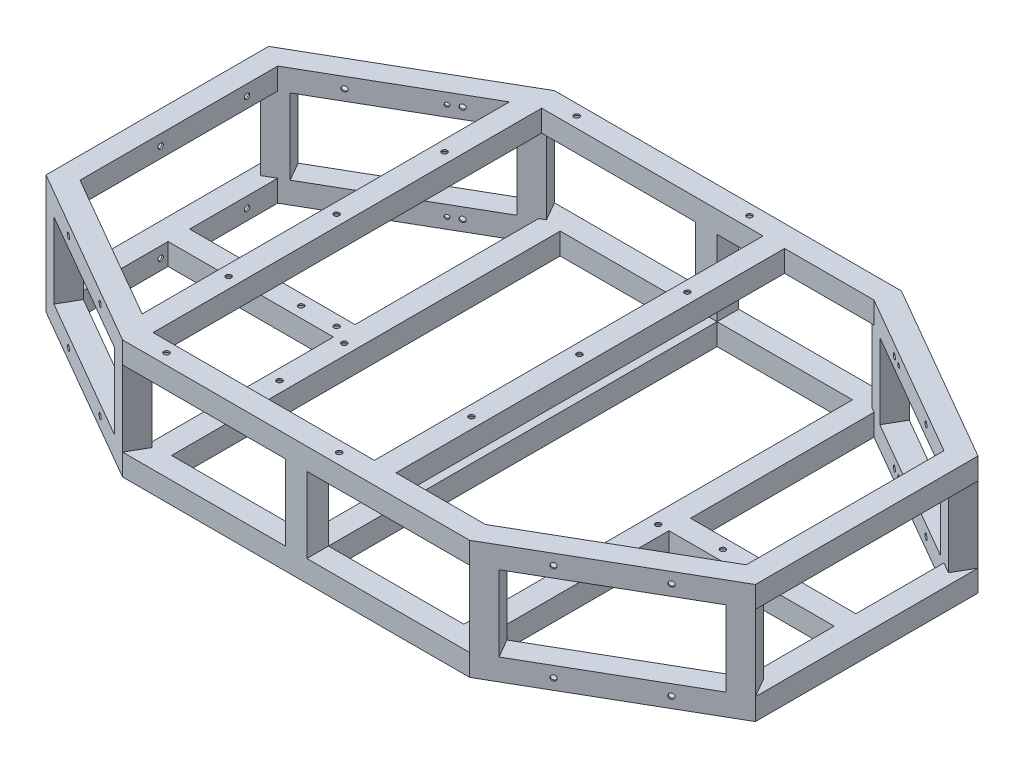
from build123d import *

# Parameters (mm, degrees)
SKETCH2_W                             = 25.4
SKETCH2_H                             = 25.4
SKETCH2_W_2                           = 22.098
SKETCH2_H_2                           = 22.098
VERTICAL_MEMBER_1_DEPTH               = 88.9
VERTICAL_MEMBER_2_DEPTH               = 88.9
VERTICAL_MEMBERS_5_6_7_8_COPY_1_DEPTH = 88.9
VERTICAL_MEMBERS_5_6_7_8_COPY_2_DEPTH = 88.9
SKETCH6_W                             = 25.4
SKETCH6_H                             = 25.4
SKETCH6_W_2                           = 22.098
SKETCH6_H_2                           = 22.098
MIDDLE_VERTICAL_MEMBER_1_DEPTH        = 88.9
SKETCH7_W                             = 25.4
SKETCH7_H                             = 25.4
SKETCH7_W_2                           = 22.098
SKETCH7_H_2                           = 22.098
MIDDLE_SUPPORT_DEPTH                  = 457.2
SKETCH8_W                             = 25.4
SKETCH8_H                             = 25.4
SKETCH8_W_2                           = 22.098
SKETCH8_H_2                           = 22.098
BOTTOM_SUPPORT_REAR_DEPTH             = 457.2
SKETCH9_W                             = 25.4
SKETCH9_H                             = 25.4
SKETCH9_W_2                           = 22.098
SKETCH9_H_2                           = 22.098
I_BEAM_DEPTH                          = 194.570453
SKETCH10_W                            = 25.4
SKETCH10_H                            = 25.4
SKETCH10_W_2                          = 22.098
SKETCH10_H_2                          = 22.098
TOP_REAR_SUPPORT_DEPTH                = 457.2
F_1_4_0_25_DIAMETER_HOLE_1_D          = 6.35
F_1_4_0_25_DIAMETER_HOLE_3_AT_2_COUNT = 2
F_1_4_0_25_DIAMETER_HOLE_3_AT_2_PITCH = 203.2
F_1_4_0_25_DIAMETER_HOLE3_AT_2_COUNT  = 2
F_1_4_0_25_DIAMETER_HOLE3_AT_2_PITCH  = 101.6
SKETCH22_R                            = 2.54
INNER_HOLE_LOCATION_1_DEPTH           = 6.35
INNER_HOLE_LOCATION_3_COPY_1_SKETCH_R = 2.54
INNER_HOLE_LOCATION_3_COPY_1_DEPTH    = 6.35
INNER_HOLE_LOCATION_4_COPY_1_SKETCH_R = 2.54
INNER_HOLE_LOCATION_4_COPY_1_DEPTH    = 6.35
INNER_HOLE_LOCATION_4_COPY_2_SKETCH_R = 2.54
INNER_HOLE_LOCATION_4_COPY_2_DEPTH    = 6.35
INNER_HOLE_LOCATION_4_COPY_3_SKETCH_R = 2.54
INNER_HOLE_LOCATION_4_COPY_3_DEPTH    = 6.35
SKETCH23_R                            = 3.175
REAR_SHOCK_MOUNT_HOLES_DEPTH          = 26.4
SKETCH24_R                            = 1.2446
Z_DIRECTION_HOLES_DEPTH               = 1.651
SKETCH25_R                            = 1.2446
X_DIRECTION_HOLES_DEPTH               = 1.651
SKETCH26_R                            = 3.175
REAR_HOLES_DEPTH                      = 25.4
SKETCH27_R                            = 1.2446
CUT_EXTRUDE5_DEPTH                    = 1.651


with BuildPart() as part:
    # Bottom Frame: sweep along a path in Sketch3
    with BuildLine(Plane(origin=(0, 0, 0), x_dir=(1, 0, 0), z_dir=(0, 1, 0))) as bottom_frame_path:
        Line((-190.5, 203.2), (190.5, 203.2))
        Line((190.5, 203.2), (366.476362049, 101.6))
        Line((366.476362049, 101.6), (366.476362049, -101.6))
        Line((366.476362049, -101.6), (190.5, -203.2))
        Line((190.5, -203.2), (-190.5, -203.2))
        Line((-190.5, -203.2), (-366.476362049, -101.6))
        Line((-366.476362049, -101.6), (-366.476362049, 101.6))
        Line((-366.476362049, 101.6), (-190.5, 203.2))
    # Sketch2 → Bottom Frame (sweep)
    with BuildSketch(Plane(origin=(0, 0, 0), x_dir=(0, 0, -1), z_dir=(1, 0, 0))):
        with Locations((241.3, 0)):
            Rectangle(SKETCH2_W, SKETCH2_H)
        with Locations((241.3, 0)):
            Rectangle(SKETCH2_W_2, SKETCH2_H_2, mode=Mode.SUBTRACT)
    bottom_frame = sweep(path=bottom_frame_path.line, transition=Transition.RIGHT)

    # Sketch4 → Vertical Member 1 (add)
    with BuildSketch(Plane(origin=(0, 12.7, 0), x_dir=(1, 0, 0), z_dir=(0, 1, 0))):
        Polygon((-204.111818976, -254), (-226.108864232, -241.3), (-213.408864232, -219.302954744), (-191.411818976, -232.002954744), align=None)
        Polygon((-204.716126917, -251.744692058), (-223.85355629, -240.695692058), (-212.80455629, -221.558262686), (-193.667126917, -232.607262686), align=None, mode=Mode.SUBTRACT)
    vertical_member_1 = extrude(amount=VERTICAL_MEMBER_1_DEPTH)

    # Sketch5 → Vertical Member 2 (add)
    with BuildSketch(Plane(origin=(0, 12.7, 0), x_dir=(1, 0, 0), z_dir=(0, 1, 0))):
        Polygon((-417.276362049, -130.929393675), (-395.279316793, -143.629393675), (-382.579316793, -121.632348419), (-404.576362049, -108.932348419), align=None)
        Polygon((-415.021054107, -130.325085733), (-395.883624735, -141.374085733), (-384.834624735, -122.23665636), (-403.972054107, -111.18765636), align=None, mode=Mode.SUBTRACT)
    vertical_member_2 = extrude(amount=VERTICAL_MEMBER_2_DEPTH)

    # Vertical Member 3 & 4: Vertical Member 1, Vertical Member 2 across plane
    add(vertical_member_1.mirror(Plane.XY))
    add(vertical_member_2.mirror(Plane.XY))

    # Vertical Members 5, 6, 7, 8: Vertical Member 1, Vertical Member 2 across plane
    add(vertical_member_1.mirror(Plane(origin=(0, 0, 0), x_dir=(0, 0, 1), z_dir=(1, 0, 0))))
    add(vertical_member_2.mirror(Plane(origin=(0, 0, 0), x_dir=(0, 0, 1), z_dir=(1, 0, 0))))

    # Vertical Members 5, 6, 7, 8 copy 1 sketc → Vertical Members 5, 6, 7, 8 copy 1 (add)
    with BuildSketch(Plane(origin=(0, 12.7, 0), x_dir=(-1, 0, 0), z_dir=(0, 1, 0))):
        Polygon((-204.111818976, -254), (-226.108864232, -241.3), (-213.408864232, -219.302954744), (-191.411818976, -232.002954744), align=None)
        Polygon((-204.716126917, -251.744692058), (-223.85355629, -240.695692058), (-212.80455629, -221.558262686), (-193.667126917, -232.607262686), align=None, mode=Mode.SUBTRACT)
    extrude(amount=VERTICAL_MEMBERS_5_6_7_8_COPY_1_DEPTH)

    # Vertical Members 5, 6, 7, 8 copy 2 sketc → Vertical Members 5, 6, 7, 8 copy 2 (add)
    with BuildSketch(Plane(origin=(0, 12.7, 0), x_dir=(-1, 0, 0), z_dir=(0, 1, 0))):
        Polygon((-417.276362049, -130.929393675), (-395.279316793, -143.629393675), (-382.579316793, -121.632348419), (-404.576362049, -108.932348419), align=None)
        Polygon((-415.021054107, -130.325085733), (-395.883624735, -141.374085733), (-384.834624735, -122.23665636), (-403.972054107, -111.18765636), align=None, mode=Mode.SUBTRACT)
    extrude(amount=VERTICAL_MEMBERS_5_6_7_8_COPY_2_DEPTH)

    # Sketch6 → Middle Vertical Member 1 (add)
    with BuildSketch(Plane(origin=(0, 12.7, 0), x_dir=(1, 0, 0), z_dir=(0, 1, 0))):
        with Locations((0, -241.3)):
            Rectangle(SKETCH6_W, SKETCH6_H)
        with Locations((0, -241.3)):
            Rectangle(SKETCH6_W_2, SKETCH6_H_2, mode=Mode.SUBTRACT)
    middle_vertical_member_1 = extrude(amount=MIDDLE_VERTICAL_MEMBER_1_DEPTH)

    # Middle Vertical Member 2: Middle Vertical Member 1 across plane
    add(middle_vertical_member_1.mirror(Plane.XY))

    # Top Frame: Bottom Frame across plane
    add(bottom_frame.mirror(Plane.ZX.offset(57.15)))

    # Sketch7 → Middle Support (add)
    with BuildSketch(Plane(origin=(0, 0, 228.6), x_dir=(-1, 0, 0), z_dir=(0, 0, -1))):
        Rectangle(SKETCH7_W, SKETCH7_H)
        Rectangle(SKETCH7_W_2, SKETCH7_H_2, mode=Mode.SUBTRACT)
    extrude(amount=MIDDLE_SUPPORT_DEPTH)

    # Sketch8 → Bottom Support Rear (add)
    with BuildSketch(Plane(origin=(0, 0, 228.6), x_dir=(-1, 0, 0), z_dir=(0, 0, -1))):
        with Locations((184.605909488, 0)):
            Rectangle(SKETCH8_W, SKETCH8_H)
        with Locations((184.605909488, 0)):
            Rectangle(SKETCH8_W_2, SKETCH8_H_2, mode=Mode.SUBTRACT)
    bottom_support_rear = extrude(amount=BOTTOM_SUPPORT_REAR_DEPTH)

    # Sketch9 → I Beam (add)
    with BuildSketch(Plane(origin=(-391.876362049, 0, 0), x_dir=(0, 0, -1), z_dir=(1, 0, 0))):
        Rectangle(SKETCH9_W, SKETCH9_H)
        Rectangle(SKETCH9_W_2, SKETCH9_H_2, mode=Mode.SUBTRACT)
    i_beam = extrude(amount=I_BEAM_DEPTH)

    # Bottom Support Front w/ I Beam: Bottom Support Rear, I Beam across plane
    add(bottom_support_rear.mirror(Plane(origin=(0, 0, 0), x_dir=(0, 0, 1), z_dir=(1, 0, 0))))
    add(i_beam.mirror(Plane(origin=(0, 0, 0), x_dir=(0, 0, 1), z_dir=(1, 0, 0))))

    # Sketch10 → Top Rear Support (add)
    with BuildSketch(Plane(origin=(0, 0, 228.6), x_dir=(-1, 0, 0), z_dir=(0, 0, -1))):
        with Locations((206.375, 114.3)):
            Rectangle(SKETCH10_W, SKETCH10_H)
        with Locations((206.375, 114.3)):
            Rectangle(SKETCH10_W_2, SKETCH10_H_2, mode=Mode.SUBTRACT)
    top_rear_support = extrude(amount=TOP_REAR_SUPPORT_DEPTH)

    # Top Front Support: Top Rear Support across plane
    add(top_rear_support.mirror(Plane(origin=(-63.5, 0, 0), x_dir=(0, 0, 1), z_dir=(1, 0, 0))))

    # 1/4 (0.25) Diameter Hole 1 (through all)
    with Locations(Plane(origin=(0, 127, 0), x_dir=(1, 0, 0), z_dir=(0, 1, 0))):
        with Locations((-206.375, 127), (-206.375, -127), (-206.375, 0)):
            f_1_4_0_25_diameter_hole_1 = Hole(F_1_4_0_25_DIAMETER_HOLE_1_D / 2)

    # 1/4 (0.25) Diameter Hole 2: 1/4 (0.25) Diameter Hole 1 across plane
    add(f_1_4_0_25_diameter_hole_1.mirror(Plane(origin=(-63.5, 0, 0), x_dir=(0, 0, 1), z_dir=(1, 0, 0))), mode=Mode.SUBTRACT)

    # Sketch17 → 1/4 (0.25) Diameter Hole 3 (revolve, cut)
    with BuildSketch(Plane(origin=(-165.1, 127, 241.3), x_dir=(0, 0, 1), z_dir=(1, 0, 0))):
        Polygon((0, 0), (0, 52.707732465), (3.175, 50.8), (3.175, 0), align=None)
    f_1_4_0_25_diameter_hole_3 = revolve(axis=Axis((-165.1, 133.35, 241.3), (0, -1, 0)), mode=Mode.SUBTRACT)

    # 1/4 (0.25) Diameter Hole 3 at 2: 1/4 (0.25) Diameter Hole 3 ×2
    with Locations(*[(i * F_1_4_0_25_DIAMETER_HOLE_3_AT_2_PITCH, 0, 0) for i in range(1, F_1_4_0_25_DIAMETER_HOLE_3_AT_2_COUNT)]):
        add(f_1_4_0_25_diameter_hole_3, mode=Mode.SUBTRACT)

    # 1/4 (0.25) Diameter Hole 4: 1/4 (0.25) Diameter Hole 3 across plane
    add(f_1_4_0_25_diameter_hole_3.mirror(Plane.XY), mode=Mode.SUBTRACT)

    # 1/4 (0.25) Diameter Hole 4 copy 1 sketch → 1/4 (0.25) Diameter Hole 4 copy 1 (revolve, cut)
    with BuildSketch(Plane(origin=(38.1, 127, -241.3), x_dir=(0, 0, -1), z_dir=(1, 0, 0))):
        Polygon((0, 0), (0, -52.707732465), (3.175, -50.8), (3.175, 0), align=None)
    revolve(axis=Axis((38.1, 133.35, -241.3), (0, 1, 0)), mode=Mode.SUBTRACT)

    # Sketch20 → 1/4 (0.25) Diameter Hole3 (revolve, cut)
    with BuildSketch(Plane(origin=(-354.688181024, 114.3, 167.064696837), x_dir=(0.866025404, 0, 0.5), z_dir=(0, 1, 0))):
        Polygon((0, 0), (0, 52.707732465), (3.175, 50.8), (3.175, 0), align=None)
    f_1_4_0_25_diameter_hole3 = revolve(axis=Axis((-357.863181024, 114.3, 172.563958151), (0.5, 0, -0.866025404)), mode=Mode.SUBTRACT)

    # 1/4 (0.25) Diameter Hole3 at 2: 1/4 (0.25) Diameter Hole3 ×2
    with Locations(*[Vector(0.866025404, 0, 0.5) * (i * F_1_4_0_25_DIAMETER_HOLE3_AT_2_PITCH) for i in range(1, F_1_4_0_25_DIAMETER_HOLE3_AT_2_COUNT)]):
        add(f_1_4_0_25_diameter_hole3, mode=Mode.SUBTRACT)

    # Hole Location 1: 1/4 (0.25) Diameter Hole3 across plane
    add(f_1_4_0_25_diameter_hole3.mirror(Plane.ZX.offset(57.15)), mode=Mode.SUBTRACT)

    # Hole Location 1 copy 1 sketch → Hole Location 1 copy 1 (revolve, cut)
    with BuildSketch(Plane(origin=(-266.7, 0, 217.864696837), x_dir=(0.866025404, 0, 0.5), z_dir=(0, -1, 0))):
        Polygon((0, 0), (0, -52.707732465), (3.175, -50.8), (3.175, 0), align=None)
    revolve(axis=Axis((-269.875, 0, 223.363958151), (-0.5, 0, 0.866025404)), mode=Mode.SUBTRACT)

    # Hole Location 2: 1/4 (0.25) Diameter Hole3 across plane
    add(f_1_4_0_25_diameter_hole3.mirror(Plane.XY), mode=Mode.SUBTRACT)

    # Hole Location 2 copy 1 sketch → Hole Location 2 copy 1 (revolve, cut)
    with BuildSketch(Plane(origin=(-354.688181024, 0, -167.064696837), x_dir=(0.866025404, 0, -0.5), z_dir=(0, -1, 0))):
        Polygon((0, 0), (0, 52.707732465), (3.175, 50.8), (3.175, 0), align=None)
    revolve(axis=Axis((-357.863181024, 0, -172.563958151), (0.5, 0, 0.866025404)), mode=Mode.SUBTRACT)

    # Hole Location 2 copy 2 sketch → Hole Location 2 copy 2 (revolve, cut)
    with BuildSketch(Plane(origin=(-266.7, 0, -217.864696837), x_dir=(0.866025404, 0, -0.5), z_dir=(0, -1, 0))):
        Polygon((0, 0), (0, 52.707732465), (3.175, 50.8), (3.175, 0), align=None)
    revolve(axis=Axis((-269.875, 0, -223.363958151), (0.5, 0, 0.866025404)), mode=Mode.SUBTRACT)

    # Hole Location 2 copy 3 sketch → Hole Location 2 copy 3 (revolve, cut)
    with BuildSketch(Plane(origin=(-266.7, 114.3, -217.864696837), x_dir=(0.866025404, 0, -0.5), z_dir=(0, 1, 0))):
        Polygon((0, 0), (0, -52.707732465), (3.175, -50.8), (3.175, 0), align=None)
    revolve(axis=Axis((-269.875, 114.3, -223.363958151), (-0.5, 0, -0.866025404)), mode=Mode.SUBTRACT)

    # Hole Location 3: 1/4 (0.25) Diameter Hole3 across plane
    add(f_1_4_0_25_diameter_hole3.mirror(Plane(origin=(0, 0, 0), x_dir=(0, 0, 1), z_dir=(1, 0, 0))), mode=Mode.SUBTRACT)

    # Hole Location 3 copy 1 sketch → Hole Location 3 copy 1 (revolve, cut)
    with BuildSketch(Plane(origin=(354.688181024, 114.3, -167.064696837), x_dir=(-0.866025404, 0, -0.5), z_dir=(0, 1, 0))):
        Polygon((0, 0), (0, 52.707732465), (3.175, 50.8), (3.175, 0), align=None)
    revolve(axis=Axis((357.863181024, 114.3, -172.563958151), (-0.5, 0, 0.866025404)), mode=Mode.SUBTRACT)

    # Hole Location 3 copy 2 sketch → Hole Location 3 copy 2 (revolve, cut)
    with BuildSketch(Plane(origin=(354.688181024, 0, -167.064696837), x_dir=(-0.866025404, 0, -0.5), z_dir=(0, -1, 0))):
        Polygon((0, 0), (0, -52.707732465), (3.175, -50.8), (3.175, 0), align=None)
    revolve(axis=Axis((357.863181024, 0, -172.563958151), (0.5, 0, -0.866025404)), mode=Mode.SUBTRACT)

    # Hole Location 3 copy 3 sketch → Hole Location 3 copy 3 (revolve, cut)
    with BuildSketch(Plane(origin=(266.7, 0, -217.864696837), x_dir=(-0.866025404, 0, -0.5), z_dir=(0, -1, 0))):
        Polygon((0, 0), (0, -52.707732465), (3.175, -50.8), (3.175, 0), align=None)
    revolve(axis=Axis((269.875, 0, -223.363958151), (0.5, 0, -0.866025404)), mode=Mode.SUBTRACT)

    # Hole Location 3 copy 4 sketch → Hole Location 3 copy 4 (revolve, cut)
    with BuildSketch(Plane(origin=(266.7, 114.3, -217.864696837), x_dir=(-0.866025404, 0, -0.5), z_dir=(0, 1, 0))):
        Polygon((0, 0), (0, 52.707732465), (3.175, 50.8), (3.175, 0), align=None)
    revolve(axis=Axis((269.875, 114.3, -223.363958151), (-0.5, 0, 0.866025404)), mode=Mode.SUBTRACT)

    # Hole Location 3 copy 5 sketch → Hole Location 3 copy 5 (revolve, cut)
    with BuildSketch(Plane(origin=(266.7, 114.3, 217.864696837), x_dir=(-0.866025404, 0, 0.5), z_dir=(0, 1, 0))):
        Polygon((0, 0), (0, -52.707732465), (3.175, -50.8), (3.175, 0), align=None)
    revolve(axis=Axis((269.875, 114.3, 223.363958151), (0.5, 0, 0.866025404)), mode=Mode.SUBTRACT)

    # Hole Location 3 copy 6 sketch → Hole Location 3 copy 6 (revolve, cut)
    with BuildSketch(Plane(origin=(354.688181024, 0, 167.064696837), x_dir=(-0.866025404, 0, 0.5), z_dir=(0, -1, 0))):
        Polygon((0, 0), (0, 52.707732465), (3.175, 50.8), (3.175, 0), align=None)
    revolve(axis=Axis((357.863181024, 0, 172.563958151), (-0.5, 0, -0.866025404)), mode=Mode.SUBTRACT)

    # Hole Location 3 copy 7 sketch → Hole Location 3 copy 7 (revolve, cut)
    with BuildSketch(Plane(origin=(266.7, 0, 217.864696837), x_dir=(-0.866025404, 0, 0.5), z_dir=(0, -1, 0))):
        Polygon((0, 0), (0, 52.707732465), (3.175, 50.8), (3.175, 0), align=None)
    revolve(axis=Axis((269.875, 0, 223.363958151), (-0.5, 0, -0.866025404)), mode=Mode.SUBTRACT)

    # Sketch22 → Inner Hole Location 1 (cut)
    with BuildSketch(Plane(origin=(-148.313181024, 0, -256.885964967), x_dir=(0.866025404, 0, -0.5), z_dir=(0.5, 0, 0.866025404))):
        with Locations((-135.491020445, 114.3)):
            Circle(SKETCH22_R)
        with Locations((10.558979555, 114.3)):
            Circle(SKETCH22_R)
    inner_hole_location_1 = extrude(amount=-INNER_HOLE_LOCATION_1_DEPTH, mode=Mode.SUBTRACT)

    # Inner Hole Location 2: Inner Hole Location 1 across plane
    add(inner_hole_location_1.mirror(Plane.ZX.offset(57.15)), mode=Mode.SUBTRACT)

    # Inner Hole Location 3: Inner Hole Location 1 across plane
    add(inner_hole_location_1.mirror(Plane.XY), mode=Mode.SUBTRACT)

    # Inner Hole Location 3 copy 1 sketch → Inner Hole Location 3 copy 1 (cut)
    with BuildSketch(Plane(origin=(-148.313181024, 114.3, 256.885964967), x_dir=(0.866025404, 0, 0.5), z_dir=(0.5, 0, -0.866025404))):
        with Locations((-135.491020445, 114.3)):
            Circle(INNER_HOLE_LOCATION_3_COPY_1_SKETCH_R)
        with Locations((10.558979555, 114.3)):
            Circle(INNER_HOLE_LOCATION_3_COPY_1_SKETCH_R)
    extrude(amount=-INNER_HOLE_LOCATION_3_COPY_1_DEPTH, mode=Mode.SUBTRACT)

    # Inner Hole Location 4: Inner Hole Location 1 across plane
    add(inner_hole_location_1.mirror(Plane(origin=(0, 0, 0), x_dir=(0, 0, 1), z_dir=(1, 0, 0))), mode=Mode.SUBTRACT)

    # Inner Hole Location 4 copy 1 sketch → Inner Hole Location 4 copy 1 (cut)
    with BuildSketch(Plane(origin=(148.313181024, 0, 256.885964967), x_dir=(-0.866025404, 0, 0.5), z_dir=(-0.5, 0, -0.866025404))):
        with Locations((-135.491020445, 114.3)):
            Circle(INNER_HOLE_LOCATION_4_COPY_1_SKETCH_R)
        with Locations((10.558979555, 114.3)):
            Circle(INNER_HOLE_LOCATION_4_COPY_1_SKETCH_R)
    extrude(amount=-INNER_HOLE_LOCATION_4_COPY_1_DEPTH, mode=Mode.SUBTRACT)

    # Inner Hole Location 4 copy 2 sketch → Inner Hole Location 4 copy 2 (cut)
    with BuildSketch(Plane(origin=(148.313181024, 114.3, 256.885964967), x_dir=(-0.866025404, 0, 0.5), z_dir=(-0.5, 0, -0.866025404))):
        with Locations((-135.491020445, -114.3)):
            Circle(INNER_HOLE_LOCATION_4_COPY_2_SKETCH_R)
        with Locations((10.558979555, -114.3)):
            Circle(INNER_HOLE_LOCATION_4_COPY_2_SKETCH_R)
    extrude(amount=-INNER_HOLE_LOCATION_4_COPY_2_DEPTH, mode=Mode.SUBTRACT)

    # Inner Hole Location 4 copy 3 sketch → Inner Hole Location 4 copy 3 (cut)
    with BuildSketch(Plane(origin=(148.313181024, 114.3, -256.885964967), x_dir=(-0.866025404, 0, -0.5), z_dir=(-0.5, 0, 0.866025404))):
        with Locations((-135.491020445, 114.3)):
            Circle(INNER_HOLE_LOCATION_4_COPY_3_SKETCH_R)
        with Locations((10.558979555, 114.3)):
            Circle(INNER_HOLE_LOCATION_4_COPY_3_SKETCH_R)
    extrude(amount=-INNER_HOLE_LOCATION_4_COPY_3_DEPTH, mode=Mode.SUBTRACT)

    # Sketch23 → Rear Shock Mount Holes (cut, through all)
    with BuildSketch(Plane(origin=(0, 12.7, 0), x_dir=(1, 0, 0), z_dir=(0, 1, 0))):
        with Locations((-248.105909488, 0)):
            Circle(SKETCH23_R)
        with Locations((-184.605909488, -88.9)):
            Circle(SKETCH23_R)
        with Locations((-184.605909488, -12.7)):
            Circle(SKETCH23_R)
    rear_shock_mount_holes = extrude(amount=-REAR_SHOCK_MOUNT_HOLES_DEPTH, mode=Mode.SUBTRACT)

    # Front Shock Mount Holes: Rear Shock Mount Holes across plane
    add(rear_shock_mount_holes.mirror(Plane(origin=(0, 0, 0), x_dir=(0, 0, 1), z_dir=(1, 0, 0))), mode=Mode.SUBTRACT)

    # Sketch24 → Z Direction Holes (cut)
    with BuildSketch(Plane.XZ.offset(-101.6)):
        with Locations((-206.375, 190.5)):
            Circle(SKETCH24_R)
        with Locations((-206.375, 165.1)):
            Circle(SKETCH24_R)
        with Locations((-206.375, 63.5)):
            Circle(SKETCH24_R)
        with Locations((-206.375, 38.1)):
            Circle(SKETCH24_R)
        with Locations((-206.375, -165.1)):
            Circle(SKETCH24_R)
        with Locations((-206.375, -190.5)):
            Circle(SKETCH24_R)
        with Locations((79.375, 190.5)):
            Circle(SKETCH24_R)
        with Locations((79.375, 165.1)):
            Circle(SKETCH24_R)
        with Locations((79.375, 63.5)):
            Circle(SKETCH24_R)
        with Locations((79.375, 38.1)):
            Circle(SKETCH24_R)
        with Locations((79.375, -165.1)):
            Circle(SKETCH24_R)
        with Locations((79.375, -190.5)):
            Circle(SKETCH24_R)
    extrude(amount=-Z_DIRECTION_HOLES_DEPTH, mode=Mode.SUBTRACT)

    # Sketch25 → X Direction Holes (cut)
    with BuildSketch(Plane.XZ.offset(-101.6)):
        with Locations((75.288181024, -241.3)):
            Circle(SKETCH25_R)
        with Locations((49.888181024, -241.3)):
            Circle(SKETCH25_R)
        with Locations((-176.888181024, -241.3)):
            Circle(SKETCH25_R)
        with Locations((-202.288181024, -241.3)):
            Circle(SKETCH25_R)
        with Locations((-176.888181024, 241.3)):
            Circle(SKETCH25_R)
        with Locations((-202.288181024, 241.3)):
            Circle(SKETCH25_R)
        with Locations((49.888181024, 241.3)):
            Circle(SKETCH25_R)
        with Locations((75.288181024, 241.3)):
            Circle(SKETCH25_R)
    extrude(amount=-X_DIRECTION_HOLES_DEPTH, mode=Mode.SUBTRACT)

    # Sketch26 → Rear Holes (cut)
    with BuildSketch(Plane.ZY.offset(417.276362049)):
        with Locations((-80.129393675, 114.3)):
            Circle(SKETCH26_R)
        with Locations((21.470606325, 114.3)):
            Circle(SKETCH26_R)
        with Locations((21.470606325, 0)):
            Circle(SKETCH26_R)
        with Locations((-80.129393675, 0)):
            Circle(SKETCH26_R)
    extrude(amount=-REAR_HOLES_DEPTH, mode=Mode.SUBTRACT)

    # Sketch27 → Cut-Extrude5 (cut)
    with BuildSketch(Plane.XZ.offset(12.7)):
        with Locations((-184.553818976, -241.3)):
            Circle(SKETCH27_R)
        with Locations((-66.189818976, -241.3)):
            Circle(SKETCH27_R)
        with Locations((55.222181024, -241.3)):
            Circle(SKETCH27_R)
        with Locations((176.888181024, -241.3)):
            Circle(SKETCH27_R)
        with Locations((298.554181024, -241.3)):
            Circle(SKETCH27_R)
        with Locations((419.966181024, -241.3)):
            Circle(SKETCH27_R)
        with Locations((184.553818976, -241.3)):
            Circle(SKETCH27_R)
        with Locations((-404.576362049, -123.563393675)):
            Circle(SKETCH27_R)
        with Locations((404.576362049, -123.563393675)):
            Circle(SKETCH27_R)
        with Locations((404.576362049, 123.563393675)):
            Circle(SKETCH27_R)
        with Locations((184.553818976, 241.3)):
            Circle(SKETCH27_R)
        with Locations((419.966181024, 241.3)):
            Circle(SKETCH27_R)
        with Locations((298.554181024, 241.3)):
            Circle(SKETCH27_R)
        with Locations((176.888181024, 241.3)):
            Circle(SKETCH27_R)
        with Locations((55.222181024, 241.3)):
            Circle(SKETCH27_R)
        with Locations((-66.189818976, 241.3)):
            Circle(SKETCH27_R)
        with Locations((-184.553818976, 241.3)):
            Circle(SKETCH27_R)
        with Locations((-404.576362049, 123.563393675)):
            Circle(SKETCH27_R)
    extrude(amount=-CUT_EXTRUDE5_DEPTH, mode=Mode.SUBTRACT)


solid = part.part
